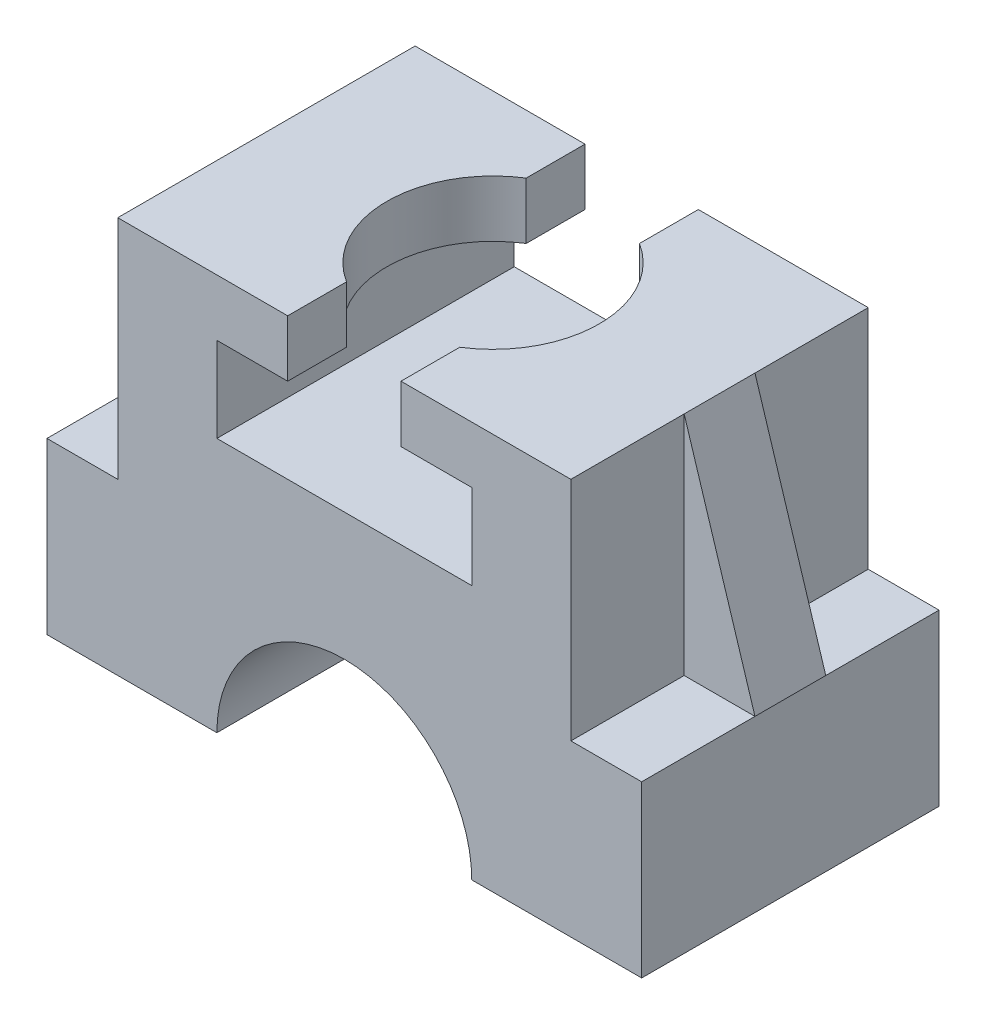
from build123d import *

# Parameters (mm, degrees)
BOSS_EXTRUDE1_DEPTH = 52.5
CUT_EXTRUDE1_START  = -20
SKETCH2_R           = 37.5
CUT_EXTRUDE1_DEPTH  = 20
BOSS_EXTRUDE2_DEPTH = 12.5
BOSS_EXTRUDE3_DEPTH = 12.5


with BuildPart() as part:
    # Sketch1 → Boss-Extrude1 (new body, symmetric)
    with BuildSketch(Plane.XY):
        with BuildLine():
            Line((45, 0), (105, 0))
            Line((105, 0), (105, 60))
            Line((105, 60), (80, 60))
            Line((80, 60), (80, 140))
            Line((80, 140), (20, 140))
            Line((20, 140), (20, 120))
            Line((20, 120), (45, 120))
            Line((45, 120), (45, 90))
            Line((45, 90), (-45, 90))
            Line((-45, 90), (-45, 120))
            Line((-45, 120), (-20, 120))
            Line((-20, 120), (-20, 140))
            Line((-20, 140), (-80, 140))
            Line((-80, 140), (-80, 60))
            Line((-80, 60), (-105, 60))
            Line((-105, 60), (-105, 0))
            Line((-105, 0), (-45, 0))
            ThreePointArc((-45, 0), (0, 45), (45, 0))
        make_face()
    extrude(amount=BOSS_EXTRUDE1_DEPTH, both=True)

    # Sketch2 → Cut-Extrude1 (cut)
    with BuildSketch(Plane(origin=(0, 140, 0), x_dir=(1, 0, 0), z_dir=(0, 1, 0)).offset(CUT_EXTRUDE1_START)):
        Circle(SKETCH2_R)
    extrude(amount=CUT_EXTRUDE1_DEPTH, mode=Mode.SUBTRACT)

    # Sketch3 → Boss-Extrude2 (add, symmetric)
    with BuildSketch(Plane.XY):
        Polygon((105, 60), (80, 60), (80, 140), align=None)
    extrude(amount=BOSS_EXTRUDE2_DEPTH, both=True)

    # Sketch4 → Boss-Extrude3 (add, symmetric)
    with BuildSketch(Plane.XY):
        Polygon((-105, 60), (-80, 60), (-80, 140), align=None)
    extrude(amount=BOSS_EXTRUDE3_DEPTH, both=True)


solid = part.part
